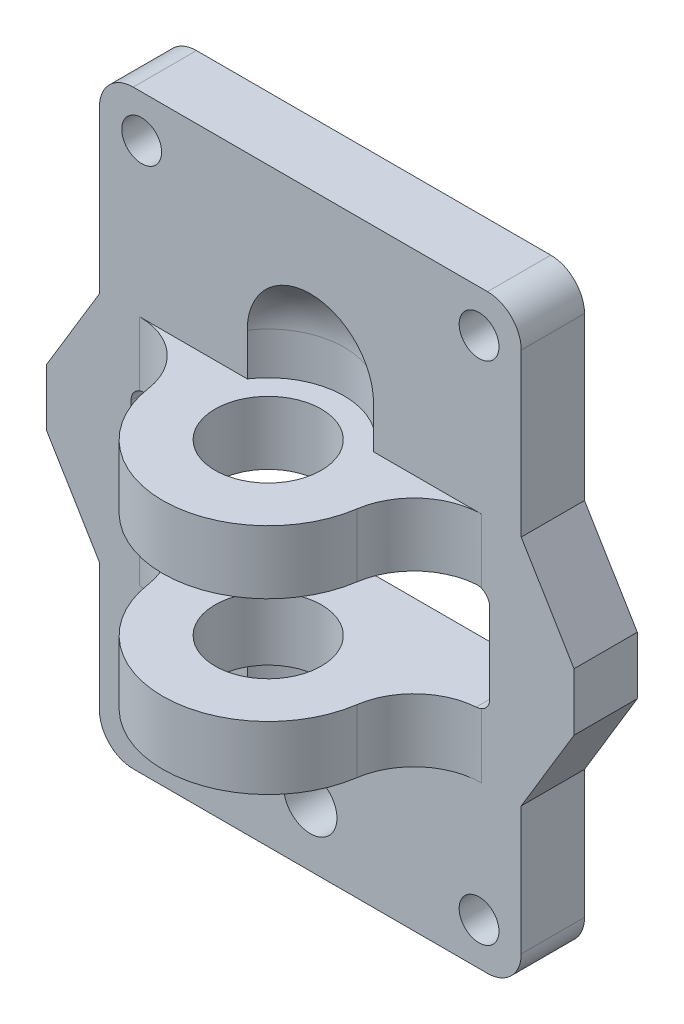
from build123d import *

# Parameters (mm, degrees)
SKETCH1_W            = 31.75
SKETCH1_H            = 44.45
BOSS_EXTRUDE1_DEPTH  = 4.7625
SKETCH2_R            = 1.5
SKETCH2_R_2          = 2
CUT_EXTRUDE1_DEPTH   = 5.7625
FILLET1_R            = 2.54
SKETCH3_W            = 27
SKETCH3_H            = 8
CUT_EXTRUDE2_DEPTH   = 5.7625
FILLET2_R            = 1
SKETCH4_R            = 7.9375
SKETCH4_R_2          = 4
BOSS_EXTRUDE2_DEPTH  = 4.7625
SKETCH5_R            = 4
CUT_EXTRUDE3_DEPTH   = 4.7625
SKETCH6_R            = 5.715
CUT_EXTRUDE4_DEPTH   = 3.175
CUT_REVOLVE1_ANGLE   = 90
FILLET3_R            = 5.08
FILLET3_OF_MIRROR1_R = 5.08
BOSS_EXTRUDE3_DEPTH  = 4.7625


with BuildPart() as part:
    # Sketch1 → Boss-Extrude1 (new body)
    with BuildSketch(Plane.XY):
        Rectangle(SKETCH1_W, SKETCH1_H)
    extrude(amount=BOSS_EXTRUDE1_DEPTH)

    # Sketch2 → Cut-Extrude1 (cut, through all)
    with BuildSketch(Plane.XY.offset(4.7625)):
        with Locations((-12.7, 19.05)):
            Circle(SKETCH2_R)
        with Locations((12.7, 19.05)):
            Circle(SKETCH2_R)
        with Locations((0, -17.78)):
            Circle(SKETCH2_R_2)
        with Locations((12.7, -19.05)):
            Circle(SKETCH2_R)
        with Locations((-12.7, -19.05)):
            Circle(SKETCH2_R)
    extrude(amount=-CUT_EXTRUDE1_DEPTH, mode=Mode.SUBTRACT)

    # Fillet1
    fillet1_edges = [part.edges().sort_by_distance(p)[0] for p in [
        (15.875, -22.225, 2.38125),
        (-15.875, -22.225, 2.38125),
        (-15.875, 22.225, 2.38125),
        (15.875, 22.225, 2.38125),
    ]]
    fillet(fillet1_edges, radius=FILLET1_R)

    # Sketch3 → Cut-Extrude2 (cut, through all)
    with BuildSketch(Plane.XY.offset(4.7625)):
        with Locations((0, -1.27)):
            Rectangle(SKETCH3_W, SKETCH3_H)
    extrude(amount=-CUT_EXTRUDE2_DEPTH, mode=Mode.SUBTRACT)

    # Fillet2
    fillet2_edges = [part.edges().sort_by_distance(p)[0] for p in [
        (13.5, 2.73, 2.38125),
        (13.5, -5.27, 2.38125),
        (-13.5, -5.27, 2.38125),
        (-13.5, 2.73, 2.38125),
    ]]
    fillet(fillet2_edges, radius=FILLET2_R)

    # Sketch4 → Boss-Extrude2 (add)
    with BuildSketch(Plane.XZ.offset(-2.73)):
        with Locations((0, 7.9375)):
            Circle(SKETCH4_R)
        with Locations((0, 7.9375)):
            Circle(SKETCH4_R_2, mode=Mode.SUBTRACT)
    boss_extrude2 = extrude(amount=-BOSS_EXTRUDE2_DEPTH)

    # Sketch5 → Cut-Extrude3 (cut)
    with BuildSketch(Plane.XZ.offset(-2.73)):
        with Locations((0, 7.9375)):
            Circle(SKETCH5_R)
    cut_extrude3 = extrude(amount=-CUT_EXTRUDE3_DEPTH, mode=Mode.SUBTRACT)

    # Sketch6 → Cut-Extrude4 (cut)
    with BuildSketch(Plane.XZ.offset(-7.4925)):
        with Locations((0, 7.9375)):
            Circle(SKETCH6_R)
    cut_extrude4 = extrude(amount=-CUT_EXTRUDE4_DEPTH, mode=Mode.SUBTRACT)

    # Sketch7 → Cut-Revolve1 (revolve, cut)
    with BuildSketch(Plane.XZ.offset(-10.6675)):
        with BuildLine():
            Line((5.715, 7.9375), (-5.715, 7.9375))
            ThreePointArc((-5.715, 7.9375), (0, 2.2225), (5.715, 7.9375))
        make_face()
    revolve(axis=Axis((5.715, 10.6675, 7.9375), (1, 0, 0)), revolution_arc=CUT_REVOLVE1_ANGLE, mode=Mode.SUBTRACT)

    # Fillet3
    fillet3_edges = [part.edges().sort_by_distance(p)[0] for p in [
        (7.274838916, 5.11125, 4.7625),
        (-7.274838916, 5.11125, 4.7625),
    ]]
    fillet(fillet3_edges, radius=FILLET3_R)

    # Mirror1: Boss-Extrude2, Cut-Extrude3, Cut-Extrude4 across plane
    add(boss_extrude2.mirror(Plane(origin=(0, -1.27, 0), x_dir=(0, 0, 1), z_dir=(0, -1, 0))))
    add(cut_extrude3.mirror(Plane(origin=(0, -1.27, 0), x_dir=(0, 0, 1), z_dir=(0, -1, 0))), mode=Mode.SUBTRACT)
    add(cut_extrude4.mirror(Plane(origin=(0, -1.27, 0), x_dir=(0, 0, 1), z_dir=(0, -1, 0))), mode=Mode.SUBTRACT)

    # Fillet3 of Mirror1
    fillet3_of_mirror1_edges = [part.edges().sort_by_distance(p)[0] for p in [
        (7.274838916, -7.65125, 4.7625),
        (-7.274838916, -7.65125, 4.7625),
    ]]
    fillet(fillet3_of_mirror1_edges, radius=FILLET3_OF_MIRROR1_R)

    # Sketch9 → Boss-Extrude3 (add)
    with BuildSketch(Plane.XY.offset(4.7625)):
        Polygon((-15.875, 7.4925), (-19.85, 0.897185125), (-19.85, -3.437185125), (-15.875, -10.0325), align=None)
    boss_extrude3 = extrude(amount=-BOSS_EXTRUDE3_DEPTH)

    # Mirror2: Boss-Extrude3 across plane
    add(boss_extrude3.mirror(Plane(origin=(0, 0, 0), x_dir=(0, 0, 1), z_dir=(1, 0, 0))))


solid = part.part
